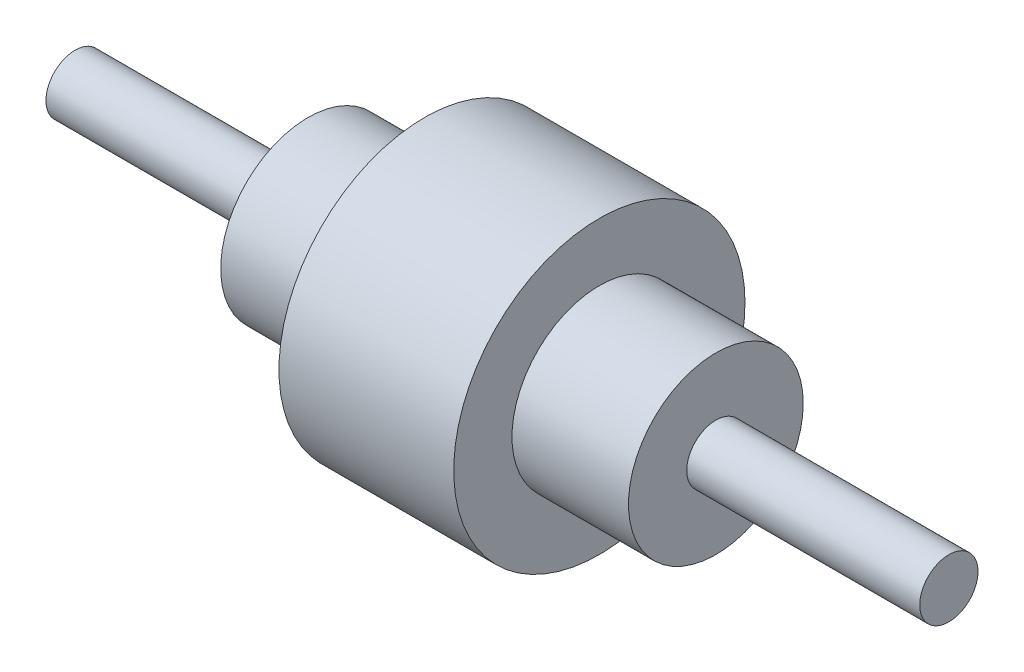
from build123d import *


with BuildPart() as part:
    # Sketch2 → Revolve1 (revolve)
    with BuildSketch(Plane(origin=(0, 0, 0), x_dir=(1, 0, 0), z_dir=(0, 1, 0)), mode=Mode.PRIVATE) as revolve1_sk:
        Polygon((45.011364727, -30), (45.011364727, -50), (105.011364727, -50), (105.011364727, -30), (145.011364727, -30), (145.011364727, -10), (225.011364727, -10), (225.011364727, 0), (-74.988635273, 0), (-74.988635273, -10), (5.011364727, -10), (5.011364727, -30), align=None)
    revolve(revolve1_sk.sketch.rotate(Axis((0, 0, 0), (-1, 0, 0)), 180), axis=Axis((0, 0, 0), (-1, 0, 0)))  # turned: the seam where the file's is


solid = part.part
